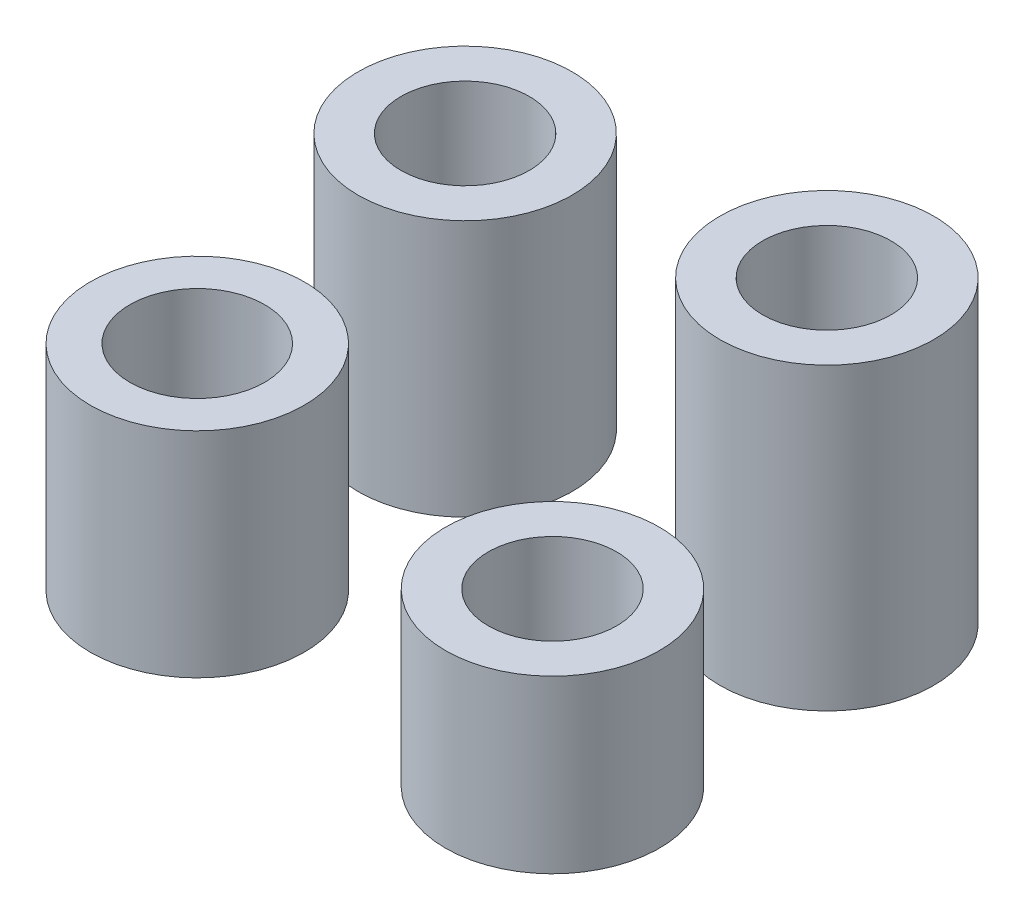
from build123d import *

# Parameters (mm, degrees)
SKETCH1_R           = 2.5
SKETCH1_R_2         = 1.575
BOSS_EXTRUDE1_DEPTH = 5
SKETCH2_R           = 2.5
SKETCH2_R_2         = 1.5
BOSS_EXTRUDE2_DEPTH = 4
SKETCH3_R           = 2.5
SKETCH3_R_2         = 1.5
BOSS_EXTRUDE3_DEPTH = 6
SKETCH4_R           = 2.5
SKETCH4_R_2         = 1.5
BOSS_EXTRUDE4_DEPTH = 7


with BuildPart() as part:
    # Sketch1 → Boss-Extrude1 (new body)
    with BuildSketch(Plane(origin=(0, 0, 0), x_dir=(1, 0, 0), z_dir=(0, 1, 0))):
        with Locations(Location((-43.569408025, 9.417348367, 0), (0, 0, 270))):  # turned: the seam where the file's is
            Circle(SKETCH1_R)
        with Locations(Location((-43.569408025, 9.417348367, 0), (0, 0, 270))):  # turned: the seam where the file's is
            Circle(SKETCH1_R_2, mode=Mode.SUBTRACT)
    extrude(amount=BOSS_EXTRUDE1_DEPTH)


with BuildPart() as body_2:
    # Sketch2 → Boss-Extrude2 (new body)
    with BuildSketch(Plane(origin=(0, 0, 0), x_dir=(1, 0, 0), z_dir=(0, 1, 0))):
        with Locations(Location((-35.45314898, 9.602309879, 0), (0, 0, 270))):  # turned: the seam where the file's is
            Circle(SKETCH2_R)
        with Locations(Location((-35.45314898, 9.602309879, 0), (0, 0, 270))):  # turned: the seam where the file's is
            Circle(SKETCH2_R_2, mode=Mode.SUBTRACT)
    extrude(amount=BOSS_EXTRUDE2_DEPTH)


with BuildPart() as body_3:
    # Sketch3 → Boss-Extrude3 (new body)
    with BuildSketch(Plane(origin=(0, 0, 0), x_dir=(1, 0, 0), z_dir=(0, 1, 0))):
        with Locations(Location((-43.69103714, 15.798498794, 0), (0, 0, 270))):  # turned: the seam where the file's is
            Circle(SKETCH3_R)
        with Locations(Location((-43.69103714, 15.798498794, 0), (0, 0, 270))):  # turned: the seam where the file's is
            Circle(SKETCH3_R_2, mode=Mode.SUBTRACT)
    extrude(amount=BOSS_EXTRUDE3_DEPTH)


with BuildPart() as body_4:
    # Sketch4 → Boss-Extrude4 (new body)
    with BuildSketch(Plane(origin=(0, 0, 0), x_dir=(1, 0, 0), z_dir=(0, 1, 0))):
        with Locations(Location((-35.542029736, 16.102915737, 0), (0, 0, 270))):  # turned: the seam where the file's is
            Circle(SKETCH4_R)
        with Locations(Location((-35.542029736, 16.102915737, 0), (0, 0, 270))):  # turned: the seam where the file's is
            Circle(SKETCH4_R_2, mode=Mode.SUBTRACT)
    extrude(amount=BOSS_EXTRUDE4_DEPTH)


solid = Compound([part.part, body_2.part, body_3.part, body_4.part])
